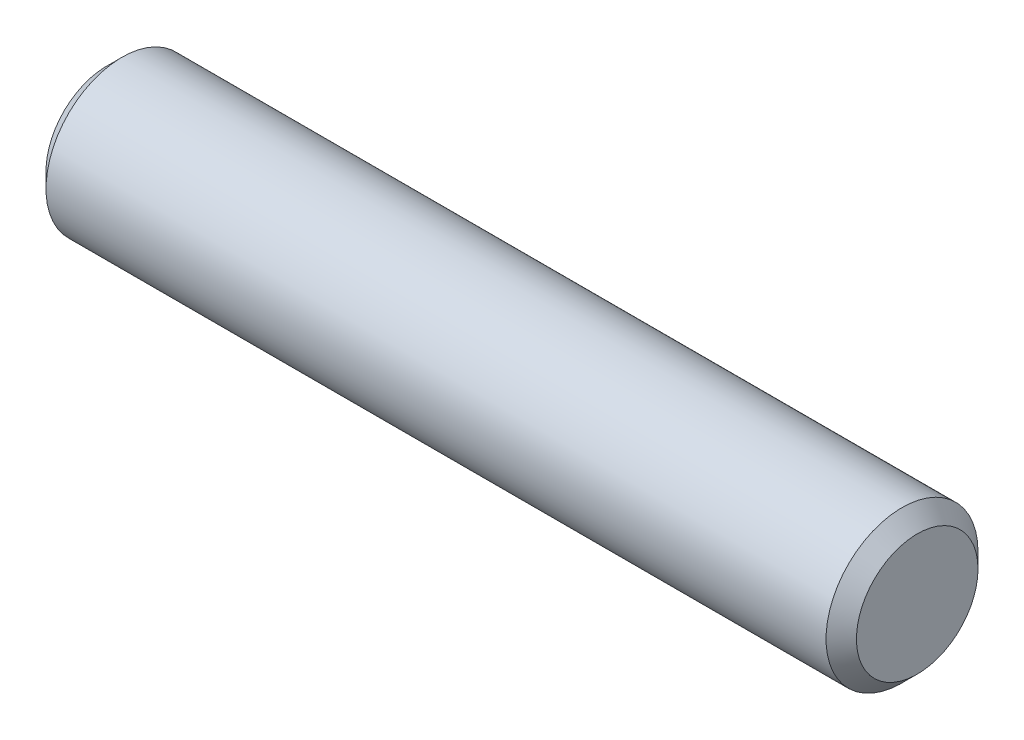
from build123d import *

# Parameters (mm, degrees)
SKETCH2_R           = 1.190625
EXTRUDE1_DEPTH      = 6.35
EXTRUDE1_DEPTH_BACK = 6.35
CHAMFER1_SIZE       = 0.238125


with BuildPart() as part:
    # Sketch2 → Extrude1 (new body, two sides)
    with BuildSketch(Plane(origin=(0, 0, 0), x_dir=(0, 0, -1), z_dir=(1, 0, 0))) as extrude1_sk:
        Circle(SKETCH2_R)
    extrude(amount=EXTRUDE1_DEPTH)
    extrude(extrude1_sk.sketch, amount=-EXTRUDE1_DEPTH_BACK)

    # Chamfer1
    chamfer1_edges = [part.edges().sort_by_distance(p)[0] for p in [
        (-6.35, 0, 1.190625),
        (6.35, 0, 1.190625),
    ]]
    chamfer(chamfer1_edges, length=CHAMFER1_SIZE)


solid = part.part
